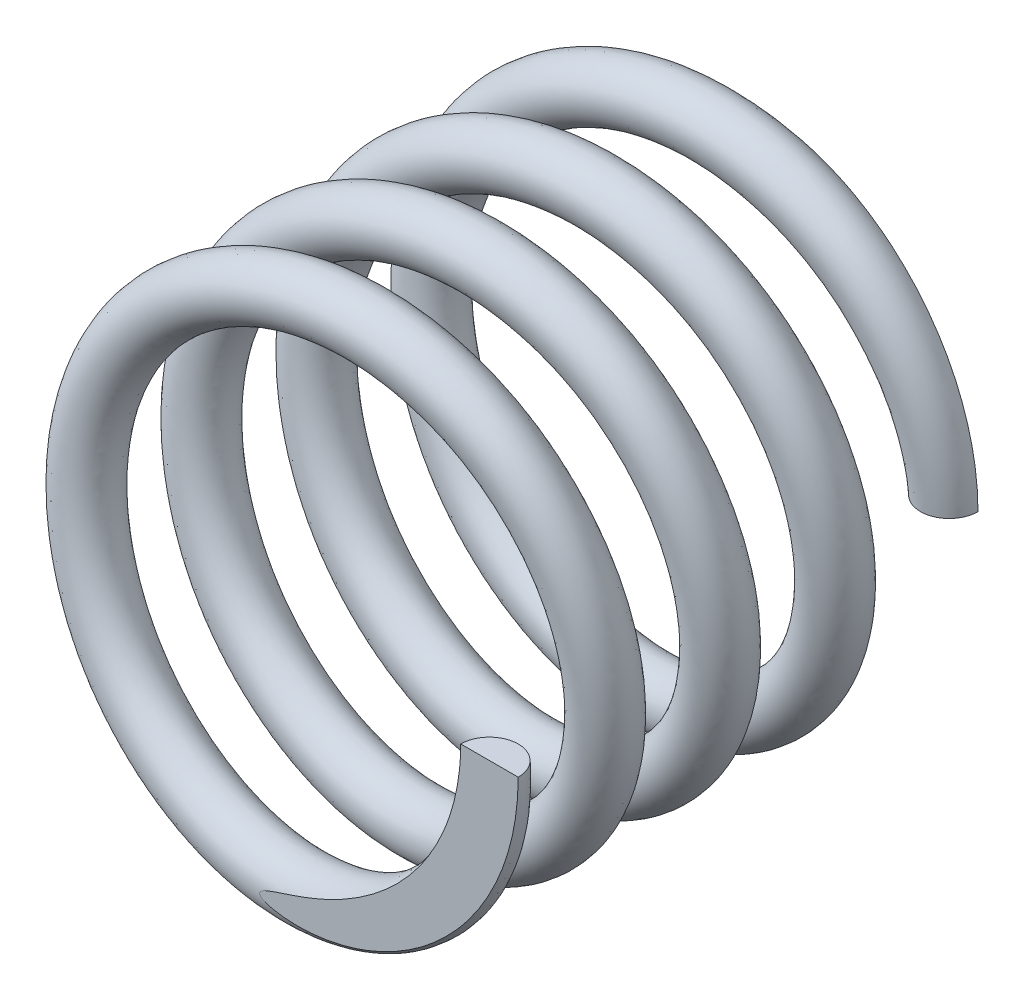
from build123d import *

# Parameters (mm, degrees)
SWEEP_1_PITCH       = 1
SWEEP_1_HEIGHT      = 4
SWEEP_1_RADIUS      = 2
SWEEP_1_START_ANGLE = 180
SKETCH_2_R          = 0.25
CUT_EXTRUDE_1_DEPTH = 3.250012831
CUT_EXTRUDE_2_DEPTH = 10


with BuildPart() as part:
    # 扫描1: sweep along a helix
    with BuildLine() as sweep_1_path:
        add(Helix(SWEEP_1_PITCH, SWEEP_1_HEIGHT, SWEEP_1_RADIUS, center=(0, 0, 0), direction=(0, 0, -1), mode=Mode.PRIVATE).rotate(Axis((0, 0, 0), (0, 0, -1)), SWEEP_1_START_ANGLE))
    # 草图2 → 扫描1 (sweep)
    with BuildSketch(Plane(origin=(0, 0, 0), x_dir=(1, 0, 0), z_dir=(0, 1, 0))):
        with Locations((2, 0)):
            Circle(SKETCH_2_R)
    sweep(path=sweep_1_path.line, is_frenet=True)

    # 草图4 → 切除-拉伸1 (cut, through all)
    with BuildSketch(Plane(origin=(0, 0, 0), x_dir=(1, 0, 0), z_dir=(0, 1, 0))):
        Polygon((-2.108710965, 0), (2.25, 0), (2.25, -0.48170249), align=None)
    extrude(amount=-CUT_EXTRUDE_1_DEPTH, mode=Mode.SUBTRACT)

    # 草图5 → 切除-拉伸2 (cut)
    with BuildSketch(Plane.XZ):
        Polygon((2.314896029, -4.461436408), (2.314896029, -4), (-1.693437337, -4), align=None)
    extrude(amount=-CUT_EXTRUDE_2_DEPTH, mode=Mode.SUBTRACT)


solid = part.part
